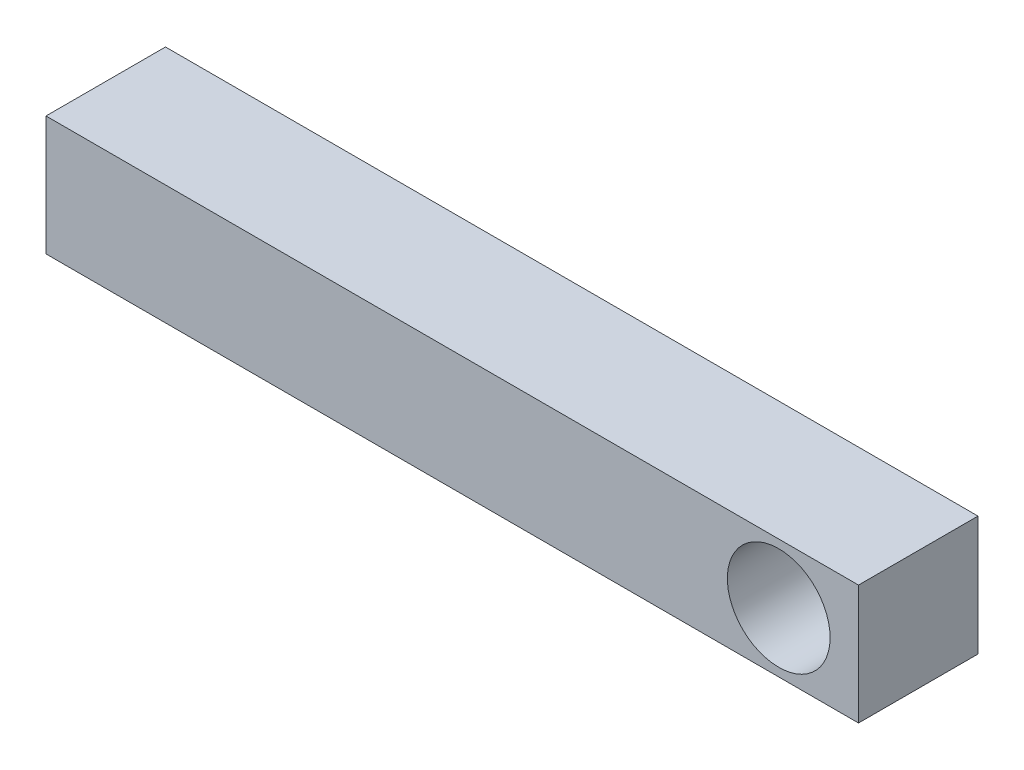
from build123d import *

# Parameters (mm, degrees)
SKETCH_1_W          = 34
SKETCH_1_H          = 5
EXTRUDE_1_DEPTH     = 5
SKETCH_2_R          = 2.149775198
CUT_EXTRUDE_1_DEPTH = 5


with BuildPart() as part:
    # 草图1 → 凸台-拉伸1 (new body)
    with BuildSketch(Plane.XY):
        Rectangle(SKETCH_1_W, SKETCH_1_H)
    extrude(amount=EXTRUDE_1_DEPTH)

    # 草图2 → 切除-拉伸1 (cut)
    with BuildSketch(Plane.XY.offset(5)):
        with Locations((13.661606897, 0)):
            Circle(SKETCH_2_R)
    extrude(amount=-CUT_EXTRUDE_1_DEPTH, mode=Mode.SUBTRACT)


solid = part.part
